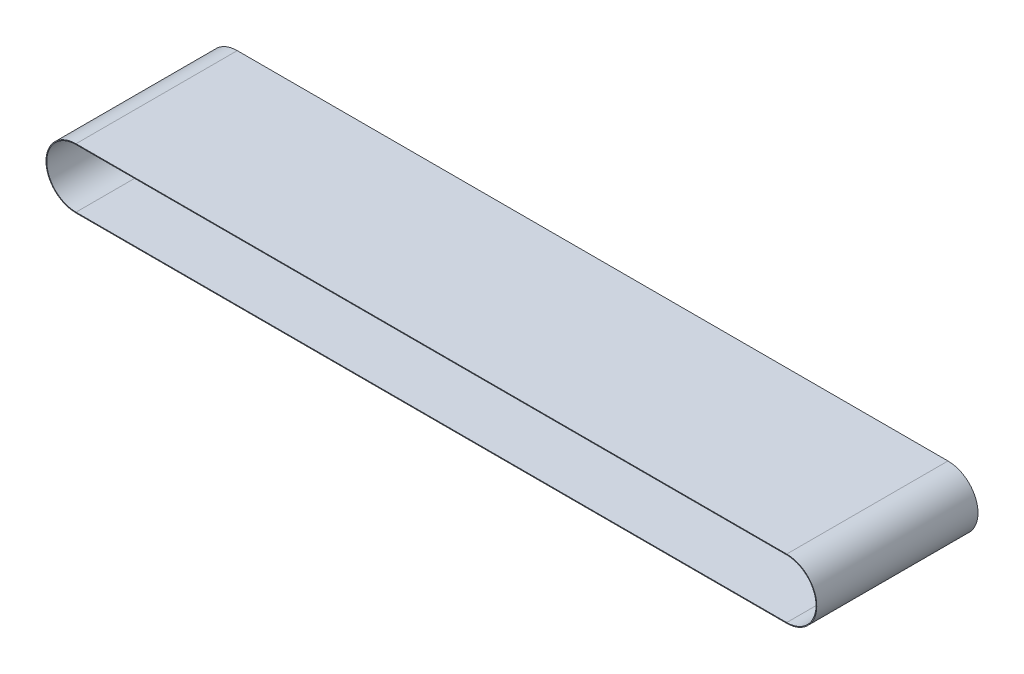
from build123d import *

# Parameters (mm, degrees)
RESSALTO_EXTRUS_O1_DEPTH = 76


with BuildPart() as part:
    # Esboço1 → Ressalto-extrusão1 (new body)
    with BuildSketch(Plane.XY):
        with BuildLine():
            Line((-167.5, 14.15), (167.5, 14.15))
            ThreePointArc((167.5, 14.15), (181.65, 0), (167.5, -14.15))
            Line((167.5, -14.15), (-167.5, -14.15))
            ThreePointArc((-167.5, -14.15), (-181.65, 0), (-167.5, 14.15))
        make_face()
        with BuildLine():
            Line((-167.5, 13.8), (167.5, 13.8))
            ThreePointArc((167.5, 13.8), (181.3, 0), (167.5, -13.8))
            Line((167.5, -13.8), (-167.5, -13.8))
            ThreePointArc((-167.5, -13.8), (-181.3, 0), (-167.5, 13.8))
        make_face(mode=Mode.SUBTRACT)
    extrude(amount=RESSALTO_EXTRUS_O1_DEPTH)


solid = part.part
